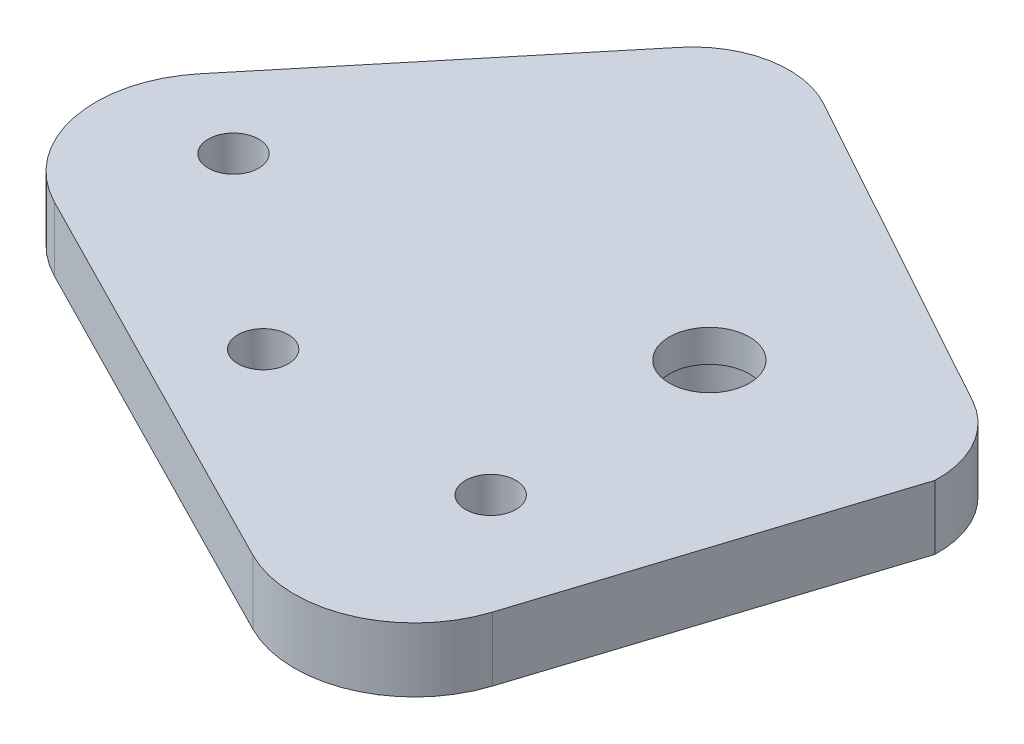
from build123d import *

# Parameters (mm, degrees)
BOSS_EXTRUDE2_DEPTH = 8
CUT_EXTRUDE5_DEPTH  = 18.5
BOSS_EXTRUDE7_DEPTH = 8
SKETCH9_R           = 3.15
CUT_EXTRUDE6_DEPTH  = 8
CUT_EXTRUDE8_DEPTH  = 8
BOSS_EXTRUDE8_DEPTH = 8
SKETCH14_R          = 5
CUT_EXTRUDE10_DEPTH = 10
SKETCH15_R          = 6
CUT_EXTRUDE11_DEPTH = 4
SKETCH2_R           = 3.15
CUT_EXTRUDE12_DEPTH = 48


with BuildPart() as part:
    # Sketch1 → Boss-Extrude2 (new body)
    with BuildSketch(Plane(origin=(0, 0, 0), x_dir=(1, 0, 0), z_dir=(0, 1, 0))):
        Polygon((-36.064195387, 30.19821093), (-36.064195387, 45.055140387), (-24.456215945, 60.508200645), (25.928290152, 75.028423128), (63.192701615, 49.978777876), (57.8600206, 4.654046233), (5.024212079, -12.575443702), (-26.79369062, -0.934399252), align=None)
    extrude(amount=BOSS_EXTRUDE2_DEPTH)

    # Sketch7 → Cut-Extrude5 (cut)
    with BuildSketch(Plane(origin=(0, 8, 0), x_dir=(1, 0, 0), z_dir=(0, 1, 0))):
        Polygon((-23.90080129, 101.032848336), (-57.901406204, 20.736967462), (-18.158957139, -32.533824917), (87.924213713, -9.961236853), (85.311975199, 49.315634488), align=None)
        Polygon((-40.820623888, 23.42964982), (-5.371906334, -12.019067733), (42.940552226, -17.400063196), (73.057764711, 41.083606285), (-8.197554073, 82.927487203), align=None, mode=Mode.SUBTRACT)
    extrude(amount=-CUT_EXTRUDE5_DEPTH, mode=Mode.SUBTRACT)

    # Sketch8 → Boss-Extrude7 (add)
    with BuildSketch(Plane(origin=(0, 8, 0), x_dir=(1, 0, 0), z_dir=(0, 1, 0))):
        Polygon((-8.197554073, 82.927487203), (-40.820623888, 23.42964982), (-5.371906334, -12.019067733), (42.940552226, -17.400063196), (73.057764711, 41.083606285), align=None)
        Polygon((7.41963674, 62.005546744), (-9.746922841, 64.747246038), (-32.401642497, 23.42964982), (0, -4.674812176), (46.197479834, 11.841771544), (56.025503799, 35.943618774), align=None, mode=Mode.SUBTRACT)
    extrude(amount=-BOSS_EXTRUDE7_DEPTH)

    # Sketch9 → Cut-Extrude6 (cut)
    with BuildSketch(Plane(origin=(0, 0, 0), x_dir=(-1, 0, 0), z_dir=(0, -1, 0))):
        with Locations((-28.941808693, 3.473889793)):
            Circle(SKETCH9_R)
    extrude(amount=-CUT_EXTRUDE6_DEPTH, mode=Mode.SUBTRACT)

    # Sketch10 → Cut-Extrude8 (cut)
    with BuildSketch(Plane(origin=(0, 8, 0), x_dir=(1, 0, 0), z_dir=(0, 1, 0))):
        Polygon((-51.027907223, 26.499697203), (-18.337970987, 89.979258173), (70.618900133, 64.73001084), (85.862243499, 8.329361683), (41.198193823, -31.646717715), (-23.676019088, -9.814381331), align=None)
        with BuildLine():
            Line((-33.872566493, 31.841833363), (-7.610913822, 63.637460521))
            ThreePointArc((-7.610913822, 63.637460521), (-0.606725689, 67.783190008), (7.431616747, 66.506171896))
            Line((7.431616747, 66.506171896), (48.870452229, 43.677060264))
            ThreePointArc((48.870452229, 43.677060264), (53.514897305, 39.092266426), (55.073012074, 32.754799821))
            Line((55.073012074, 32.754799821), (41.706263242, -9.064889609))
            ThreePointArc((41.706263242, -9.064889609), (33.18888877, -18.343686498), (20.602861854, -17.860296318))
            Line((20.602861854, -17.860296318), (-29.950777497, 7.924950794))
            ThreePointArc((-29.950777497, 7.924950794), (-37.823070784, 18.242703419), (-34.700474084, 30.839465332))
            Line((-34.700474084, 30.839465332), (-33.872566493, 31.841833363))
        make_face(mode=Mode.SUBTRACT)
    extrude(amount=-CUT_EXTRUDE8_DEPTH, mode=Mode.SUBTRACT)

    # Sketch12 → Boss-Extrude8 (add)
    with BuildSketch(Plane(origin=(0, 8, 0), x_dir=(1, 0, 0), z_dir=(0, 1, 0))):
        with BuildLine():
            Line((-34.700474084, 30.839465332), (-23.799416497, 10.878604368))
            Line((-23.799416497, 10.878604368), (16.273254251, -10.775107124))
            Line((16.273254251, -10.775107124), (41.706263242, -9.064889609))
            ThreePointArc((41.706263242, -9.064889609), (33.18888877, -18.343686498), (20.602861854, -17.860296318))
            Line((20.602861854, -17.860296318), (-29.950777497, 7.924950794))
            ThreePointArc((-29.950777497, 7.924950794), (-37.823070784, 18.242703419), (-34.700474084, 30.839465332))
        make_face()
    extrude(amount=-BOSS_EXTRUDE8_DEPTH)

    # Sketch14 → Cut-Extrude10 (cut)
    with BuildSketch(Plane(origin=(0, 0, 0), x_dir=(-1, 0, 0), z_dir=(0, -1, 0))):
        with Locations((-28.006293823, 31.687531628)):
            Circle(SKETCH14_R)
    extrude(amount=-CUT_EXTRUDE10_DEPTH, mode=Mode.SUBTRACT)

    # Sketch15 → Cut-Extrude11 (cut)
    with BuildSketch(Plane.XZ):
        with Locations((28.006293823, -31.687531628)):
            Circle(SKETCH15_R)
    extrude(amount=-CUT_EXTRUDE11_DEPTH, mode=Mode.SUBTRACT)

    # Sketch2 → Cut-Extrude12 (cut)
    with BuildSketch(Plane(origin=(0, 8, 0), x_dir=(1, 0, 0), z_dir=(0, 1, 0))):
        with Locations((-0.992606529, 5.023658057)):
            Circle(SKETCH2_R)
        with Locations((-23.973939823, 24.307286348)):
            Circle(SKETCH2_R)
    extrude(amount=-CUT_EXTRUDE12_DEPTH, mode=Mode.SUBTRACT)


solid = part.part
